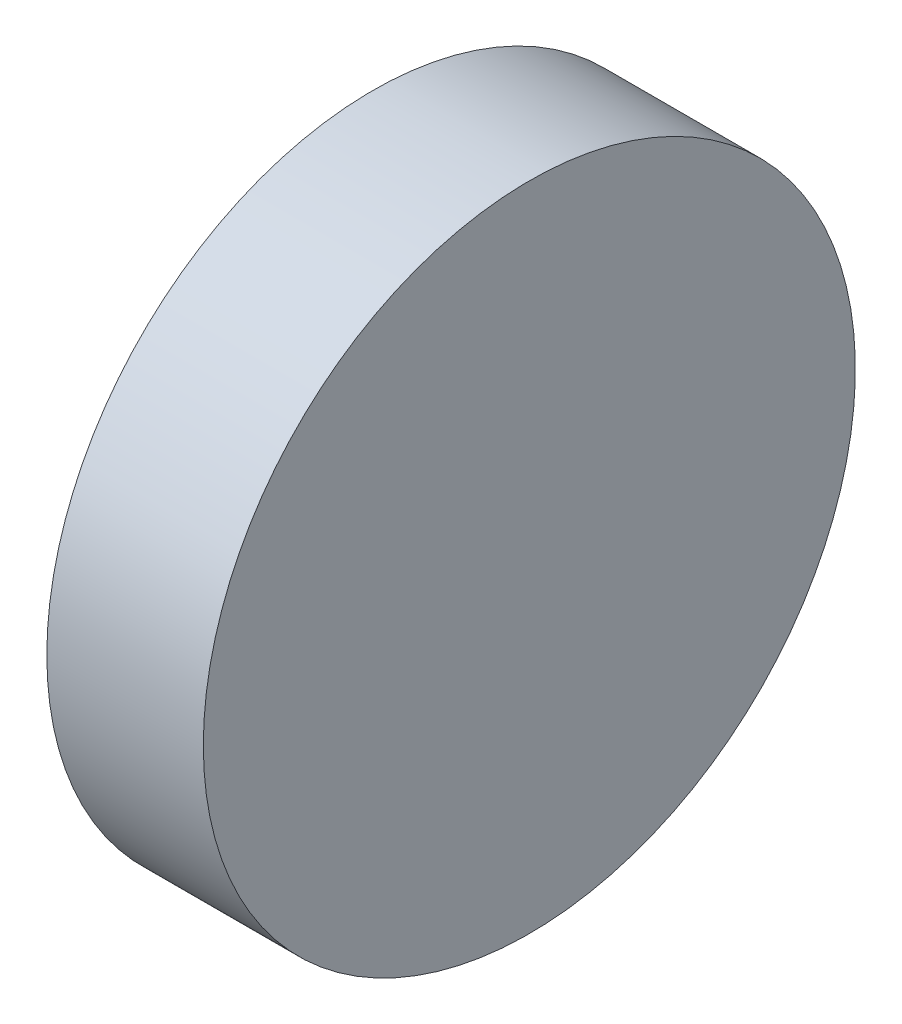
from build123d import *

# Parameters (mm, degrees)
SKETCH_1_W = 6
SKETCH_1_H = 12.5


with BuildPart() as part:
    # 草图1 → 旋转1 (revolve)
    with BuildSketch(Plane.XY, mode=Mode.PRIVATE) as revolve_1_sk:
        with Locations((263.286208168, 83.543179349)):
            Rectangle(SKETCH_1_W, SKETCH_1_H)
    revolve(revolve_1_sk.sketch.rotate(Axis((254.000801993, 77.293179349, 0), (1, 0, 0)), 90), axis=Axis((254.000801993, 77.293179349, 0), (1, 0, 0)))  # turned: the seam where the file's is


solid = part.part
